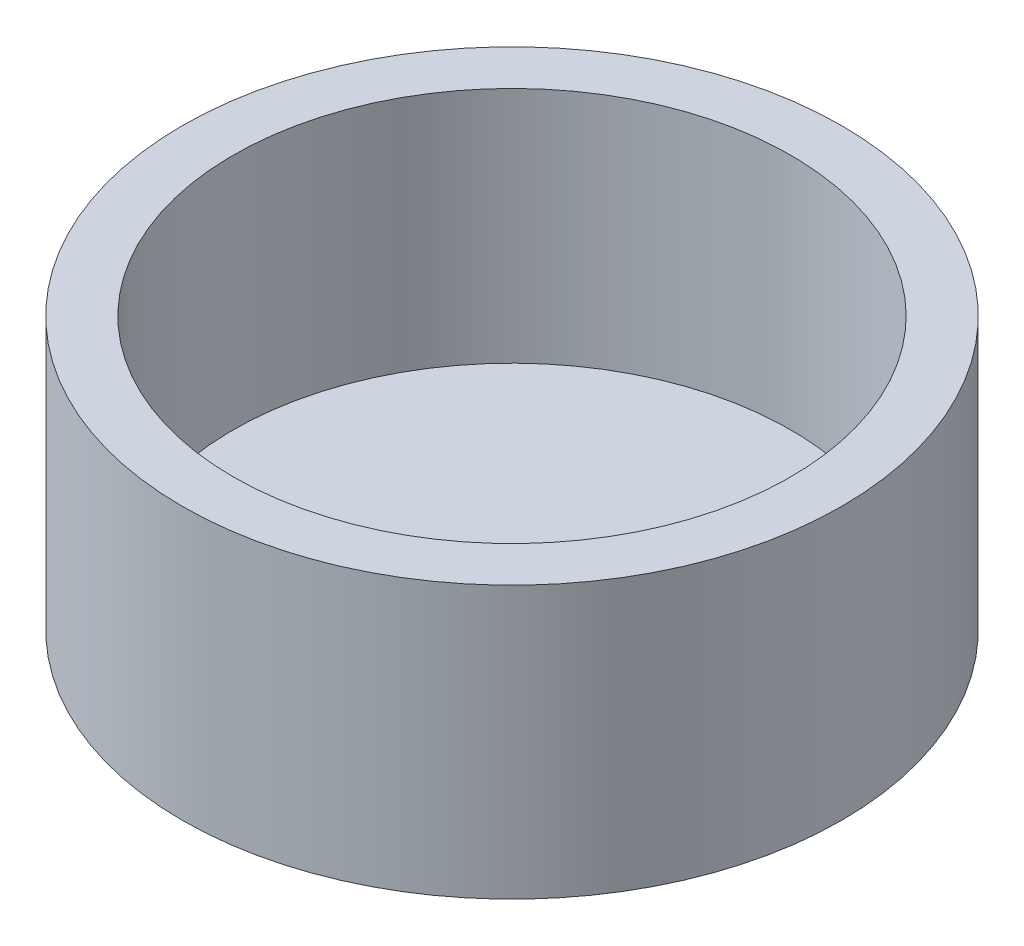
from build123d import *

# Parameters (mm, degrees)
SKETCH1_R           = 4.85
BOSS_EXTRUDE1_DEPTH = 4
SKETCH2_R           = 4.1
CUT_EXTRUDE1_DEPTH  = 3.5


with BuildPart() as part:
    # Sketch1 → Boss-Extrude1 (new body)
    with BuildSketch(Plane(origin=(0, 0, 0), x_dir=(1, 0, 0), z_dir=(0, 1, 0))):
        Circle(SKETCH1_R)
    extrude(amount=BOSS_EXTRUDE1_DEPTH)

    # Sketch2 → Cut-Extrude1 (cut)
    with BuildSketch(Plane(origin=(0, 4, 0), x_dir=(1, 0, 0), z_dir=(0, 1, 0))):
        Circle(SKETCH2_R)
    extrude(amount=-CUT_EXTRUDE1_DEPTH, mode=Mode.SUBTRACT)


solid = part.part
